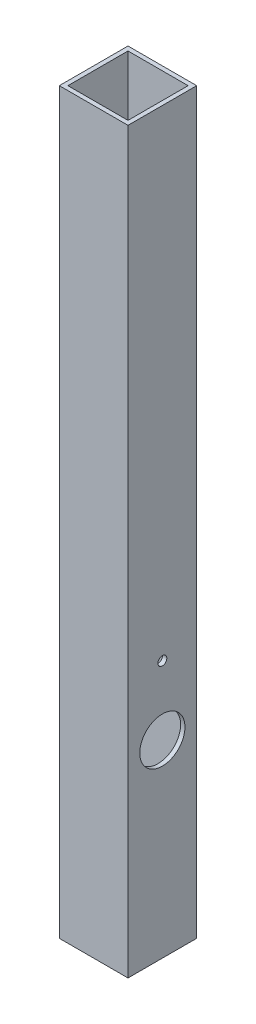
from build123d import *

# Parameters (mm, degrees)
SKETCH1_W           = 50.8
SKETCH1_H           = 546.1
BOSS_EXTRUDE1_DEPTH = 50.8
SKETCH2_W           = 44.45
SKETCH2_H           = 44.45
CUT_EXTRUDE1_DEPTH  = 547.1
SKETCH4_R           = 16.7005
SKETCH4_R_2         = 3.302
CUT_EXTRUDE2_DEPTH  = 51.8


with BuildPart() as part:
    # Sketch1 → Boss-Extrude1 (new body)
    with BuildSketch(Plane(origin=(0, 0, 0), x_dir=(0, 0, -1), z_dir=(1, 0, 0))):
        Rectangle(SKETCH1_W, SKETCH1_H)
    extrude(amount=BOSS_EXTRUDE1_DEPTH)

    # Sketch2 → Cut-Extrude1 (cut, through all)
    with BuildSketch(Plane(origin=(0, 273.05, 0), x_dir=(1, 0, 0), z_dir=(0, 1, 0))):
        with Locations((25.4, 0)):
            Rectangle(SKETCH2_W, SKETCH2_H)
    extrude(amount=-CUT_EXTRUDE1_DEPTH, mode=Mode.SUBTRACT)

    # Sketch4 → Cut-Extrude2 (cut, through all)
    with BuildSketch(Plane(origin=(50.8, 0, 0), x_dir=(0, 0, -1), z_dir=(1, 0, 0))):
        with Locations((0, -133.35)):
            Circle(SKETCH4_R)
        with Locations((0, -82.598640474)):
            Circle(SKETCH4_R_2)
    extrude(amount=-CUT_EXTRUDE2_DEPTH, mode=Mode.SUBTRACT)


solid = part.part
